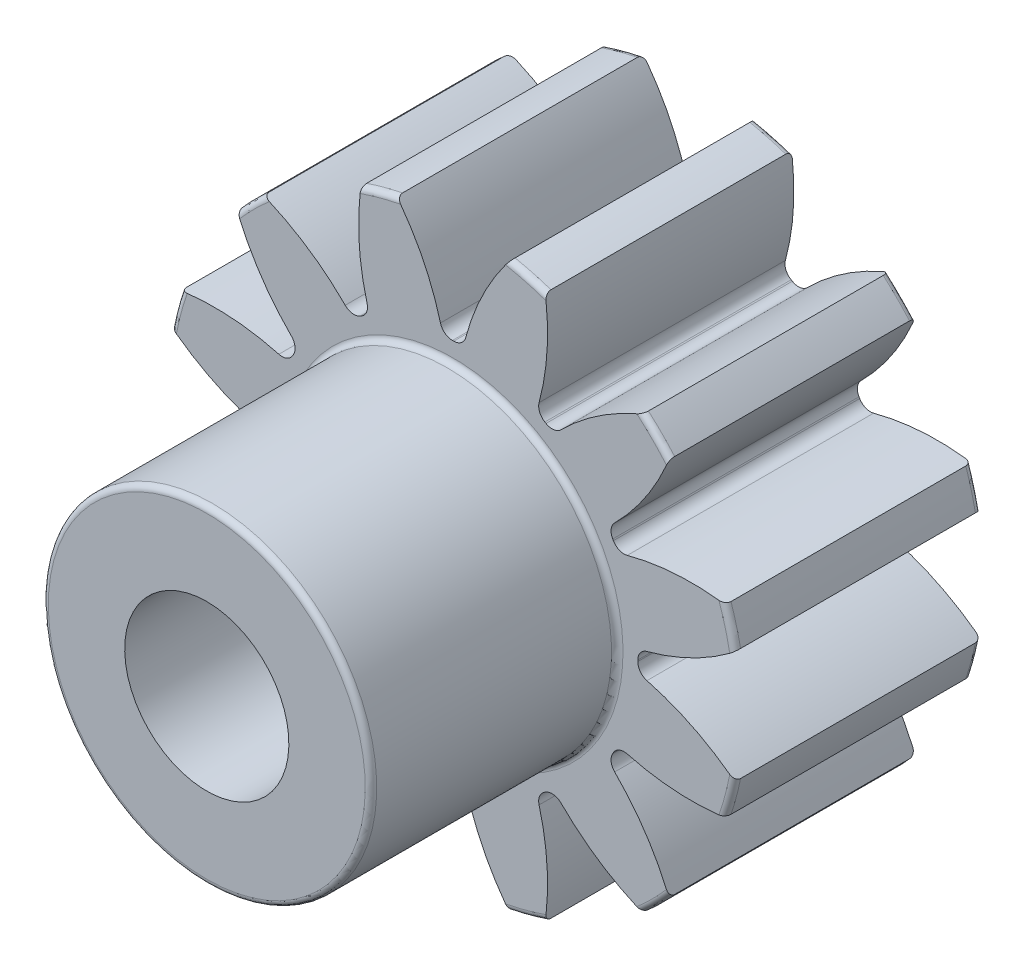
from build123d import *

# Parameters (mm, degrees)
FILLET2_R          = 0.14
CUT_EXTRUDE2_DEPTH = 7
CIRPATTERN1_COUNT  = 12


with BuildPart() as part:
    # Sketch4 → Revolve1 (revolve)
    with BuildSketch(Plane(origin=(0, 0, 0), x_dir=(0, 0, -1), z_dir=(1, 0, 0))):
        Polygon((-12, 2), (-12, 4), (-6, 4), (-6, 7), (0, 7), (0, 2), align=None)
    revolve(axis=Axis((0, 0, 6), (0, 0, 1)))

    # Fillet2
    fillet2_edges = [part.edges().sort_by_distance(p)[0] for p in [
        (0, -7, 0),
        (0, -7, 6),
        (0, -4, 6),
        (0, -4, 12),
    ]]
    fillet(fillet2_edges, radius=FILLET2_R)

    # Sketch7 → Cut-Extrude2 (cut, through all)
    with BuildSketch(Plane.XY.offset(6)):
        with BuildLine():
            ThreePointArc((-0.016433478, 4.499969993), (0, 4.5), (0.016433478, 4.499969993))
            ThreePointArc((0.016433478, 4.499969993), (0.199907289, 4.561764499), (0.307439354, 4.722755355))
            ThreePointArc((0.307439354, 4.722755355), (0.731505846, 5.847106195), (1.371117638, 6.864403574))
            ThreePointArc((1.371117638, 6.864403574), (0, 7), (-1.371117638, 6.864403574))
            ThreePointArc((-1.371117638, 6.864403574), (-0.731505846, 5.847106195), (-0.307439354, 4.722755355))
            ThreePointArc((-0.307439354, 4.722755355), (-0.199907289, 4.561764499), (-0.016433478, 4.499969993))
        make_face()
    cut_extrude2 = extrude(amount=-CUT_EXTRUDE2_DEPTH, mode=Mode.SUBTRACT)

    # CirPattern1: Cut-Extrude2 ×12 about axis
    cirpattern1_axis = Axis((0, 0, 0), (0, 0, 1))
    for i in range(1, CIRPATTERN1_COUNT):
        add(cut_extrude2.rotate(cirpattern1_axis, i * 360 / CIRPATTERN1_COUNT), mode=Mode.SUBTRACT)


solid = part.part
